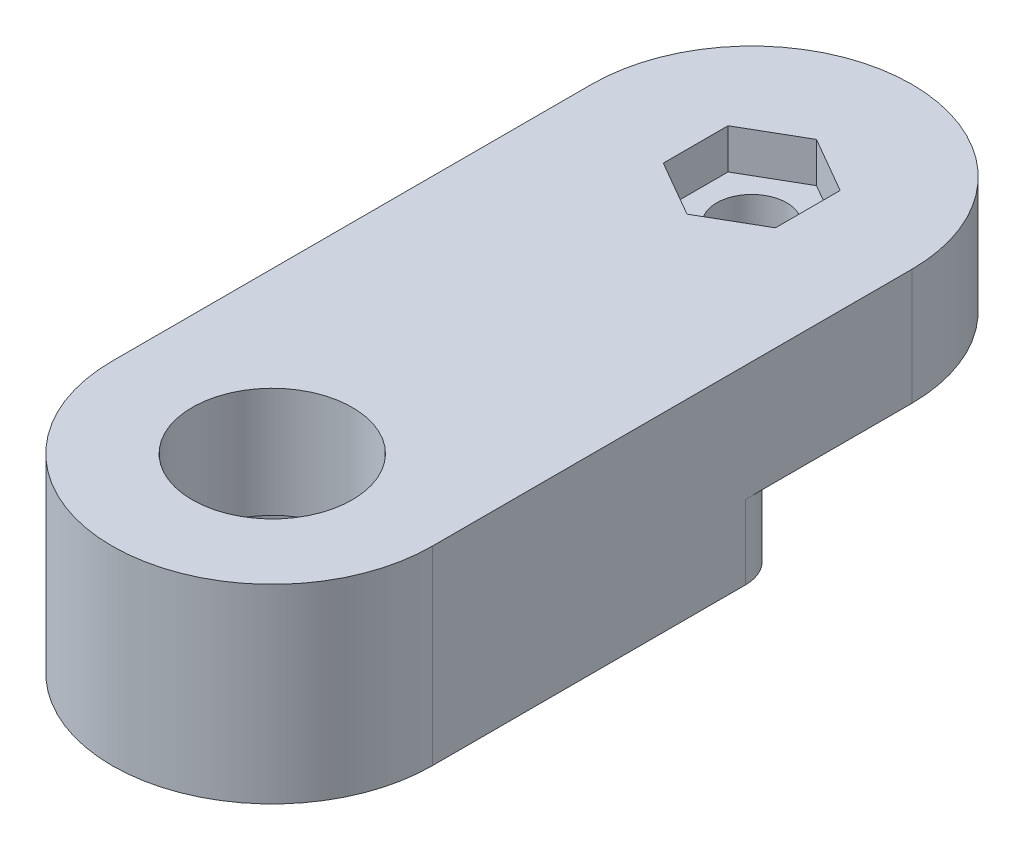
from build123d import *

# Parameters (mm, degrees)
SKETCH1_R           = 5.15
BOSS_EXTRUDE1_DEPTH = 4
SKETCH2_R           = 4
BOSS_EXTRUDE2_DEPTH = 5.5
SKETCH3_R           = 8.25
CUT_EXTRUDE1_DEPTH  = 3.7
CUT_EXTRUDE2_REACH  = 7.8
SKETCH4_R           = 1.75
SKETCH5_R           = 4.1
SKETCH5_R_2         = 1.75
BOSS_EXTRUDE3_DEPTH = 0.2
CUT_EXTRUDE3_DEPTH  = 2
FILLET1_R           = 2


with BuildPart() as part:
    # Sketch1 → Boss-Extrude1 (new body)
    with BuildSketch(Plane(origin=(0, 0, 0), x_dir=(1, 0, 0), z_dir=(0, 1, 0))):
        with BuildLine():
            Line((-8, 23.95), (-8, 0))
            ThreePointArc((-8, 0), (0, -8), (8, 0))
            Line((8, 0), (8, 23.95))
            ThreePointArc((8, 23.95), (0, 31.95), (-8, 23.95))
        make_face()
        Circle(SKETCH1_R, mode=Mode.SUBTRACT)
    extrude(amount=BOSS_EXTRUDE1_DEPTH)

    # Sketch2 → Boss-Extrude2 (add)
    with BuildSketch(Plane(origin=(0, 4, 0), x_dir=(1, 0, 0), z_dir=(0, 1, 0))):
        with BuildLine():
            Line((-8, 23.95), (-8, 0))
            ThreePointArc((-8, 0), (0, -8), (8, 0))
            Line((8, 0), (8, 23.95))
            ThreePointArc((8, 23.95), (0, 31.95), (-8, 23.95))
        make_face()
        Circle(SKETCH2_R, mode=Mode.SUBTRACT)
    extrude(amount=BOSS_EXTRUDE2_DEPTH)

    # Sketch3 → Cut-Extrude1 (cut)
    with BuildSketch(Plane(origin=(0, 0, 0), x_dir=(1, 0, 0), z_dir=(0, 1, 0))):
        with Locations((0, 23.95)):
            Circle(SKETCH3_R)
    extrude(amount=CUT_EXTRUDE1_DEPTH, mode=Mode.SUBTRACT)

    # Sketch4 → Cut-Extrude2 (cut, up to next)
    with BuildSketch(Plane.XZ.offset(-3.7), mode=Mode.PRIVATE) as cut_extrude2_sk1:
        with Locations((0, -23.95)):
            Circle(SKETCH4_R)
    cut_extrude2_tool1 = extrude(cut_extrude2_sk1.sketch, amount=-CUT_EXTRUDE2_REACH, mode=Mode.PRIVATE) & part.part
    add(cut_extrude2_tool1.solids().sort_by_distance((0, 3.7, -23.95))[0], mode=Mode.SUBTRACT)

    # Sketch5 → Boss-Extrude3 (add)
    with BuildSketch(Plane.XZ.offset(-3.7)):
        with Locations((0, -23.95)):
            Circle(SKETCH5_R)
        with Locations((0, -23.95)):
            Circle(SKETCH5_R_2, mode=Mode.SUBTRACT)
    extrude(amount=BOSS_EXTRUDE3_DEPTH)

    # Sketch6 → Cut-Extrude3 (cut)
    with BuildSketch(Plane(origin=(0, 9.5, 0), x_dir=(1, 0, 0), z_dir=(0, 1, 0))):
        Polygon((0, 20.716838493), (2.8, 22.333419246), (2.8, 25.566580754), (0, 27.183161507), (-2.8, 25.566580754), (-2.8, 22.333419246), align=None)
    extrude(amount=-CUT_EXTRUDE3_DEPTH, mode=Mode.SUBTRACT)

    # Fillet1
    fillet1_edges = [part.edges().sort_by_distance(p)[0] for p in [
        (8, 1.85, -21.934435563),
        (-8, 1.85, -21.934435563),
    ]]
    fillet(fillet1_edges, radius=FILLET1_R)


solid = part.part
